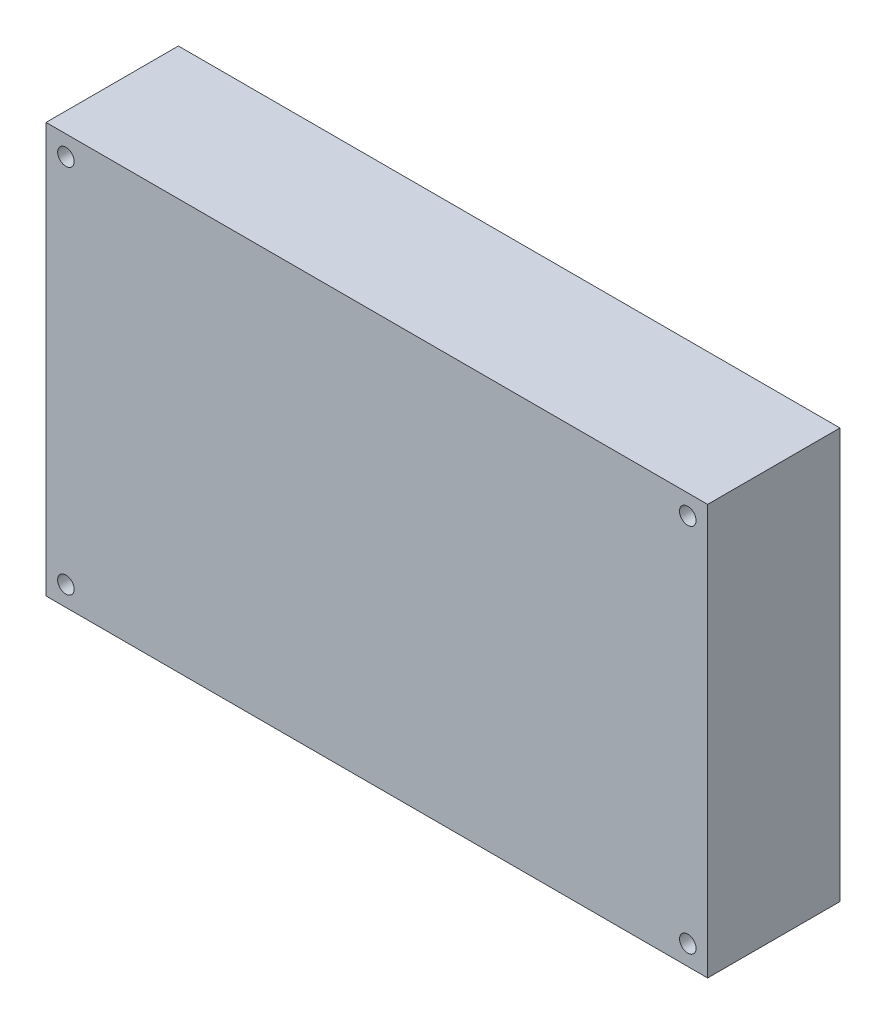
from build123d import *

# Parameters (mm, degrees)
SKETCH_1_W         = 100
SKETCH_1_H         = 62
EXTRUDE_1_DEPTH    = 20
HOLE_WIZARD_M3_1_D = 2.5


with BuildPart() as part:
    # 草图1 → 凸台-拉伸1 (new body)
    with BuildSketch(Plane.XY):
        Rectangle(SKETCH_1_W, SKETCH_1_H)
    extrude(amount=EXTRUDE_1_DEPTH)

    # M3 螺纹孔1 (through all)
    with Locations(Plane.XY.offset(20)):
        with Locations((-47, 28), (-47, -28), (47, -28), (47, 28)):
            Hole(HOLE_WIZARD_M3_1_D / 2)


solid = part.part
